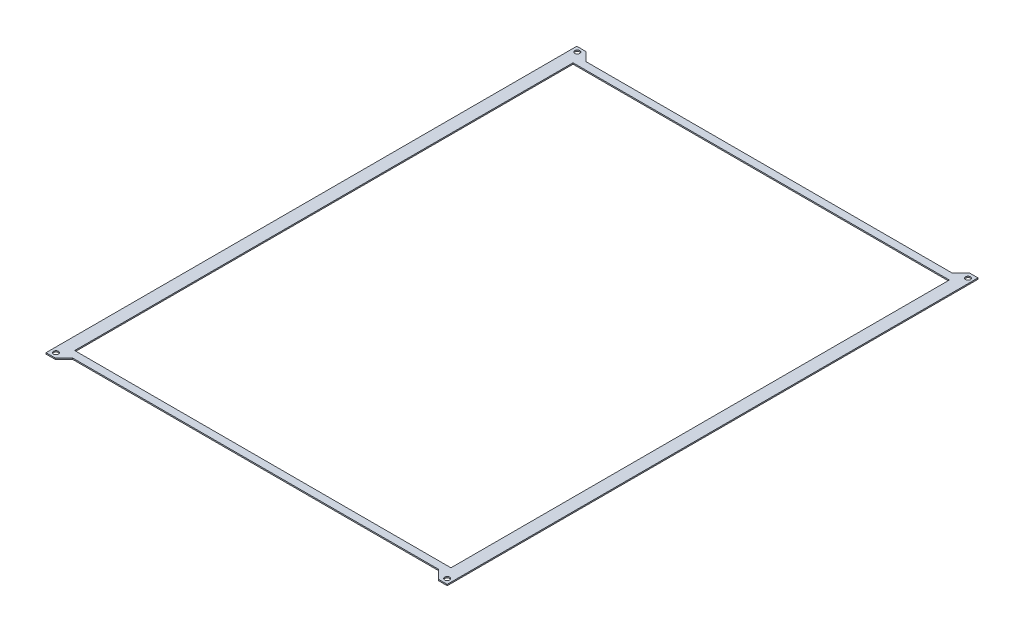
from build123d import *

# Parameters (mm, degrees)
CROQUIS1_R              = 1
CROQUIS1_W              = 151
CROQUIS1_H              = 200
SALIENTE_EXTRUIR1_DEPTH = 0.5


with BuildPart() as part:
    # Croquis1 → Saliente-Extruir1 (new body)
    with BuildSketch(Plane(origin=(0, 0, 0), x_dir=(1, 0, 0), z_dir=(0, 1, 0))):
        Polygon((-80.5, -106.4), (-80.5, -106.5), (-80.4, -106.5), (-76.9, -106.5), (-73.4, -103), (73.5, -103), (77, -106.5), (80.5, -106.5), (80.5, 106.5), (77, 106.5), (73.5, 103), (-73.4, 103), (-76.9, 106.5), (-80.5, 106.5), align=None)
        with Locations((-78.5, -104.5)):
            Circle(CROQUIS1_R, mode=Mode.SUBTRACT)
        with Locations((78.5, -104.5)):
            Circle(CROQUIS1_R, mode=Mode.SUBTRACT)
        with Locations((78.629753046, 104.40240388)):
            Circle(CROQUIS1_R, mode=Mode.SUBTRACT)
        with Locations((-78.370125817, 104.597434861)):
            Circle(CROQUIS1_R, mode=Mode.SUBTRACT)
        Rectangle(CROQUIS1_W, CROQUIS1_H, mode=Mode.SUBTRACT)
    extrude(amount=SALIENTE_EXTRUIR1_DEPTH)


solid = part.part
